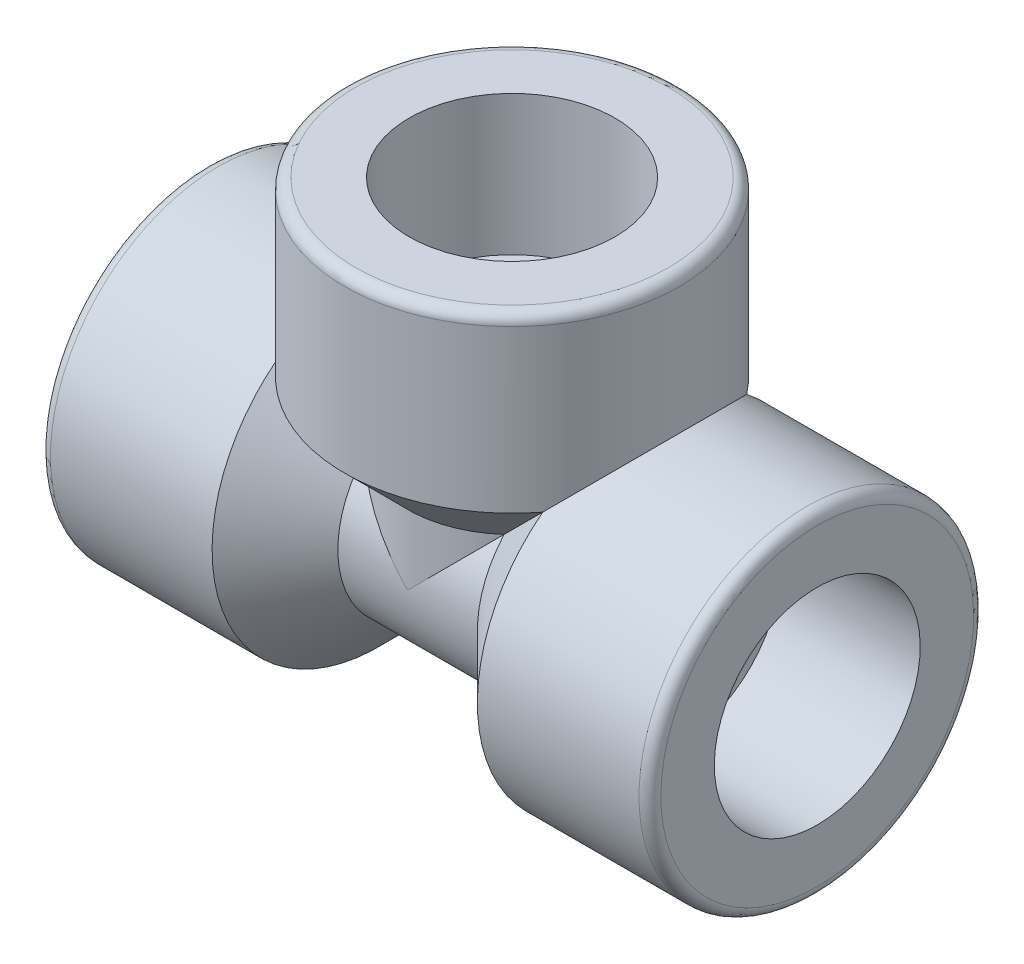
from build123d import *

# Parameters (mm, degrees)
CIRPATTERN2_COUNT       = 3
CIRPATTERN2_ANGLE       = 180
SKETCH4_R               = 4.191
CUT_EXTRUDE1_DEPTH      = 32.976017529
CUT_EXTRUDE1_DEPTH_BACK = 32.976017529
SKETCH5_R               = 4.191
CUT_EXTRUDE2_DEPTH      = 32.976017529


with BuildPart() as part:
    # Sketch2 → Revolve1 (revolve)
    with BuildSketch(Plane.XY, mode=Mode.PRIVATE) as revolve1_sk:
        with BuildLine():
            Line((-21.082, -7.112), (-11.43, -7.112))
            Line((-11.43, -7.112), (-11.43, -4.191))
            Line((-11.43, -4.191), (0, -4.191))
            Line((0, -4.191), (0, -7.2136))
            Line((0, -7.2136), (-4.81965, -7.2136))
            Line((-4.81965, -7.2136), (-9.16305, -11.557))
            Line((-9.16305, -11.557), (-20.32635, -11.557))
            ThreePointArc((-20.32635, -11.557), (-20.860675239, -11.335675239), (-21.082, -10.80135))
            Line((-21.082, -10.80135), (-21.082, -7.112))
        make_face()
    revolve(revolve1_sk.sketch.rotate(Axis((0, 0, 0), (-1, 0, 0)), 180), axis=Axis((0, 0, 0), (-1, 0, 0)))


with BuildPart() as cirpattern2_1:
    # CirPattern2: pattern copy
    add(part.part.rotate(Axis((0, 0, 0), (0, 0, -1)), 1 * CIRPATTERN2_ANGLE / (CIRPATTERN2_COUNT - 1)))

    # Sketch4 → Cut-Extrude1 (cut, two sides)
    with BuildSketch(Plane(origin=(0, 0, 0), x_dir=(0, 0, -1), z_dir=(1, 0, 0))) as cut_extrude1_sk:
        with Locations(Location((0, 0, 0), (0, 0, 270))):
            Circle(SKETCH4_R)
    extrude(amount=CUT_EXTRUDE1_DEPTH, mode=Mode.SUBTRACT)
    extrude(cut_extrude1_sk.sketch, amount=-CUT_EXTRUDE1_DEPTH_BACK, mode=Mode.SUBTRACT)


with BuildPart() as cirpattern2_2:
    # CirPattern2: pattern copy
    add(part.part.rotate(Axis((0, 0, 0), (0, 0, -1)), 2 * CIRPATTERN2_ANGLE / (CIRPATTERN2_COUNT - 1)))


with BuildPart() as part_1:
    add(part.part)

    # Combine1: union CirPattern2_1, CirPattern2_2
    add(cirpattern2_1.part)
    add(cirpattern2_2.part)

    # Sketch5 → Cut-Extrude2 (cut, through all)
    with BuildSketch(Plane(origin=(0, 0, 0), x_dir=(1, 0, 0), z_dir=(0, 1, 0))):
        Circle(SKETCH5_R)
    extrude(amount=CUT_EXTRUDE2_DEPTH, mode=Mode.SUBTRACT)


solid = part_1.part
